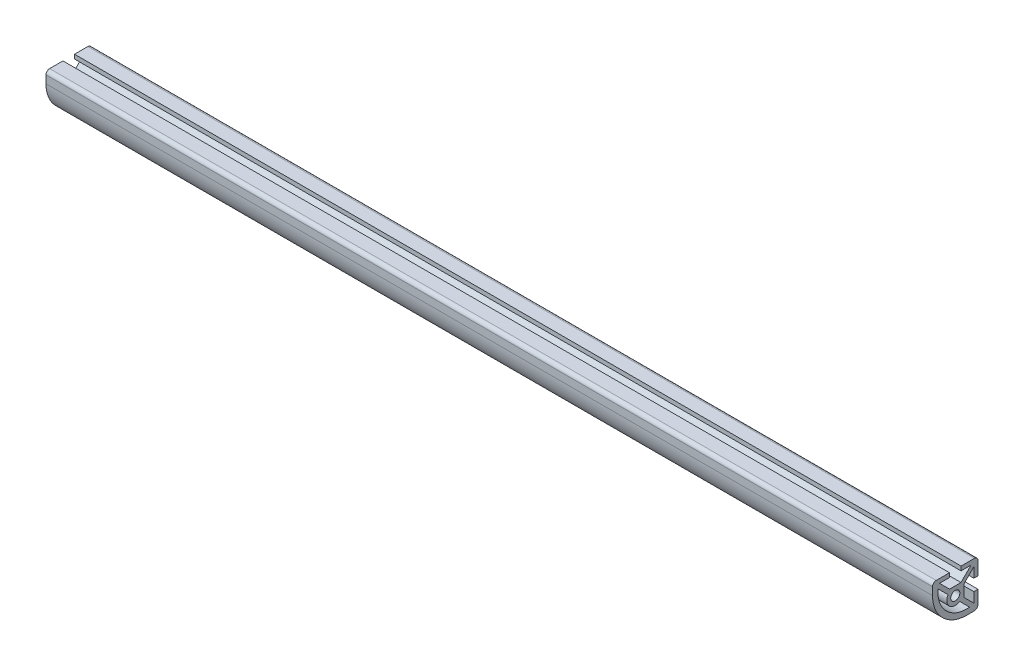
from build123d import *

# Parameters (mm, degrees)
SKETCH3_R                = 2.5527
BOSS_EXTRUDE1_DEPTH      = 247.65
BOSS_EXTRUDE1_DEPTH_BACK = 247.65


with BuildPart() as part:
    # Sketch3 → Boss-Extrude1 (new body, two sides)
    with BuildSketch(Plane(origin=(0, 0, 0), x_dir=(0, 0, -1), z_dir=(1, 0, 0))) as boss_extrude1_sk:
        with BuildLine():
            Line((-10.668, 12.7), (-3.2385, 12.7))
            Line((-3.2385, 12.7), (-3.2385, 10.3632))
            Line((-3.2385, 10.3632), (-8.800635435, 10.3632))
            Line((-8.800635435, 10.3632), (-3.187235669, 4.749800235))
            Line((-3.187235669, 4.749800235), (3.187235669, 4.749800235))
            Line((3.187235669, 4.749800235), (8.800635435, 10.3632))
            Line((8.800635435, 10.3632), (3.2385, 10.3632))
            Line((3.2385, 10.3632), (3.2385, 12.7))
            Line((3.2385, 12.7), (10.668, 12.7))
            ThreePointArc((10.668, 12.7), (12.104840979, 12.104840979), (12.7, 10.668))
            Line((12.7, 10.668), (12.7, 3.2385))
            Line((12.7, 3.2385), (10.3632, 3.2385))
            Line((10.3632, 3.2385), (10.3632, 8.800635435))
            Line((10.3632, 8.800635435), (4.749800235, 3.187235669))
            Line((4.749800235, 3.187235669), (4.749800235, -3.187235669))
            Line((4.749800235, -3.187235669), (10.3632, -8.800635435))
            Line((10.3632, -8.800635435), (10.3632, -3.2385))
            Line((10.3632, -3.2385), (12.7, -3.2385))
            Line((12.7, -3.2385), (12.7, -10.668))
            ThreePointArc((12.7, -10.668), (12.104840979, -12.104840979), (10.668, -12.7))
            Line((10.668, -12.7), (6.35, -12.7))
            ThreePointArc((6.35, -12.7), (-7.120384182, -7.120384182), (-12.7, 6.35))
            Line((-12.7, 6.35), (-12.7, 10.668))
            ThreePointArc((-12.7, 10.668), (-12.104840979, 12.104840979), (-10.668, 12.7))
        make_face()
        Circle(SKETCH3_R, mode=Mode.SUBTRACT)
        with BuildLine():
            Line((2.485198871, -4.047763436), (8.003751298, -9.566315863))
            ThreePointArc((8.003751298, -9.566315863), (-4.965122713, -4.965122713), (-9.566315863, 8.003751298))
            Line((-9.566315863, 8.003751298), (-4.047763436, 2.485198871))
            ThreePointArc((-4.047763436, 2.485198871), (-3.358615955, -3.358615955), (2.485198871, -4.047763436))
        make_face(mode=Mode.SUBTRACT)
    extrude(amount=BOSS_EXTRUDE1_DEPTH)
    extrude(boss_extrude1_sk.sketch, amount=-BOSS_EXTRUDE1_DEPTH_BACK)


solid = part.part
